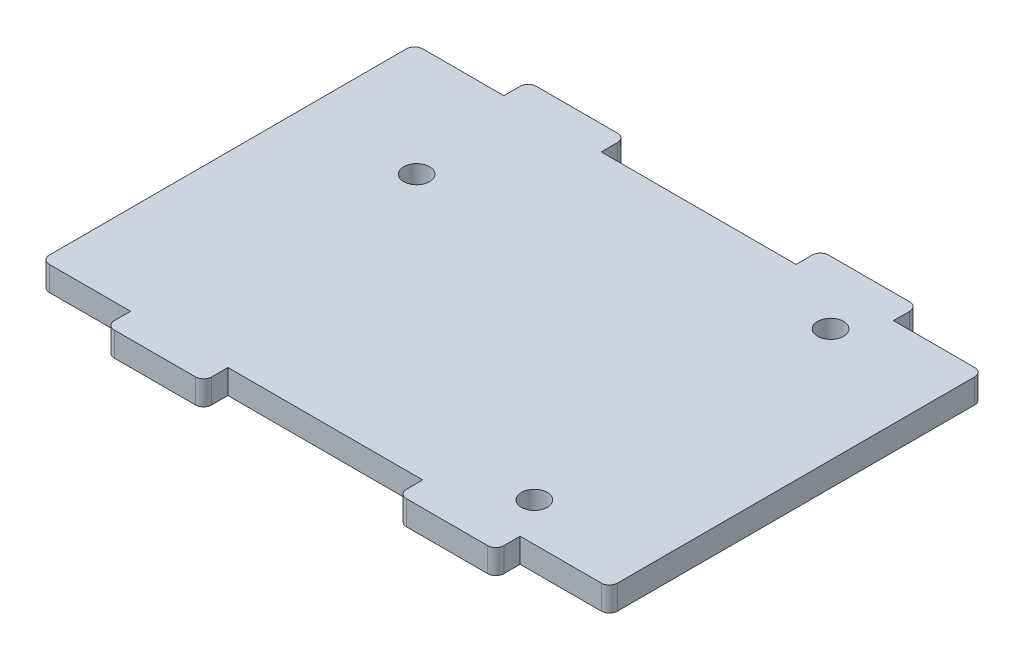
from build123d import *

# Parameters (mm, degrees)
SKETCH_1_W          = 70
SKETCH_1_H          = 52
EXTRUDE_1_DEPTH     = 3
SKETCH_2_R          = 1.6
SKETCH_2_W          = 24
SKETCH_2_H          = 6
SKETCH_2_W_2        = 11
SKETCH_2_H_2        = 3
CUT_EXTRUDE_1_DEPTH = 4
FILLET_1_R          = 1


with BuildPart() as part:
    # 草图1 → 凸台-拉伸1 (new body)
    with BuildSketch(Plane(origin=(0, 0, 0), x_dir=(1, 0, 0), z_dir=(0, 1, 0))):
        Rectangle(SKETCH_1_W, SKETCH_1_H)
    extrude(amount=EXTRUDE_1_DEPTH)

    # 草图2 → 切除-拉伸1 (cut, through all)
    with BuildSketch(Plane(origin=(0, 3, 0), x_dir=(1, 0, 0), z_dir=(0, 1, 0))):
        with Locations((-21, 9.25)):
            Circle(SKETCH_2_R)
        with Locations((21, 18.25)):
            Circle(SKETCH_2_R)
        with Locations((21, -18.25)):
            Circle(SKETCH_2_R)
        with Locations((0, 26)):
            Rectangle(SKETCH_2_W, SKETCH_2_H)
        with Locations((-29.5, 24.5)):
            Rectangle(SKETCH_2_W_2, SKETCH_2_H_2)
        with Locations((29.5, 24.5)):
            Rectangle(SKETCH_2_W_2, SKETCH_2_H_2)
        with Locations((-29.5, -24.5)):
            Rectangle(SKETCH_2_W_2, SKETCH_2_H_2)
        with Locations((29.5, -24.5)):
            Rectangle(SKETCH_2_W_2, SKETCH_2_H_2)
        with Locations((0, -26)):
            Rectangle(SKETCH_2_W, SKETCH_2_H)
    extrude(amount=-CUT_EXTRUDE_1_DEPTH, mode=Mode.SUBTRACT)

    # 圆角1
    fillet_1_edges = [part.edges().sort_by_distance(p)[0] for p in [
        (12, 1.5, -26),
        (-12, 1.5, -26),
        (-35, 1.5, -23),
        (-24, 1.5, -26),
        (35, 1.5, -23),
        (24, 1.5, -26),
        (-35, 1.5, 23),
        (-24, 1.5, 26),
        (35, 1.5, 23),
        (24, 1.5, 26),
        (-12, 1.5, 26),
        (12, 1.5, 26),
    ]]
    fillet(fillet_1_edges, radius=FILLET_1_R)


solid = part.part
